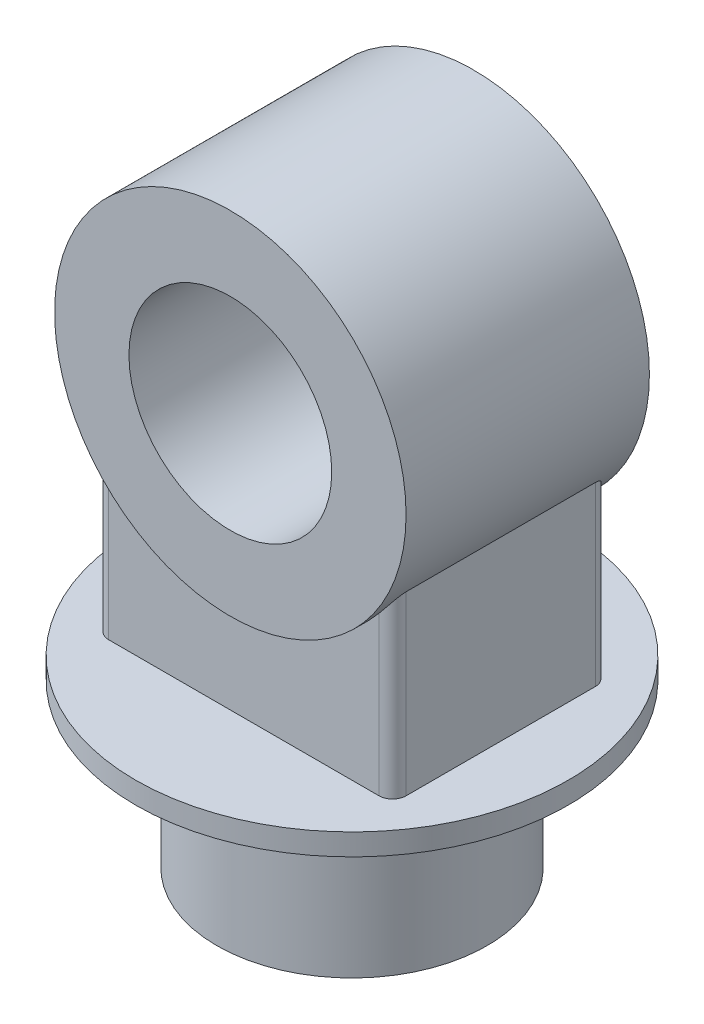
from build123d import *

# Parameters (mm, degrees)
SKETCH1_R                = 100
BOSS_EXTRUDE1_DEPTH      = 120
SKETCH2_R                = 160
BOSS_EXTRUDE2_DEPTH      = 16
SKETCH3_R                = 130
SKETCH3_R_2              = 75
BOSS_EXTRUDE3_DEPTH      = 90
BOSS_EXTRUDE4_REACH      = 402.125
BOSS_EXTRUDE4_END_RADIUS = 130
SKETCH4_W                = 220
SKETCH4_H                = 160
FILLET1_R                = 10


with BuildPart() as part:
    # Sketch1 → Boss-Extrude1 (new body)
    with BuildSketch(Plane(origin=(0, 0, 0), x_dir=(1, 0, 0), z_dir=(0, 1, 0))):
        with Locations(Location((0, 0, 0), (0, 0, 270))):
            Circle(SKETCH1_R)
    extrude(amount=BOSS_EXTRUDE1_DEPTH)

    # Sketch2 → Boss-Extrude2 (add)
    with BuildSketch(Plane(origin=(0, 120, 0), x_dir=(1, 0, 0), z_dir=(0, 1, 0))):
        with Locations(Location((0, 0, 0), (0, 0, 270))):
            Circle(SKETCH2_R)
    extrude(amount=BOSS_EXTRUDE2_DEPTH)



with BuildPart() as body_2:
    # Sketch3 → Boss-Extrude3 (new, symmetric)
    with BuildSketch(Plane.XY):
        with Locations(Location((0, 336, 0), (0, 0, 180))):
            Circle(SKETCH3_R)
        with Locations(Location((0, 336, 0), (0, 0, 180))):
            Circle(SKETCH3_R_2, mode=Mode.SUBTRACT)
    extrude(amount=BOSS_EXTRUDE3_DEPTH, both=True)


with BuildPart() as part_1:
    add(part.part)

    add(body_2.part)  # Boss-Extrude4 merges body 2
    # Boss-Extrude4: up to this cylinder (the profile starts outside it)
    boss_extrude4_end = Plane(origin=(0, 336, 0), z_dir=(0, 0, -1)) * Cylinder(BOSS_EXTRUDE4_END_RADIUS, 1065.25, mode=Mode.PRIVATE)
    # Sketch4 → Boss-Extrude4 (add, up to the surface)
    with BuildSketch(Plane(origin=(0, 136, 0), x_dir=(1, 0, 0), z_dir=(0, 1, 0)), mode=Mode.PRIVATE) as boss_extrude4_sk1:
        Rectangle(SKETCH4_W, SKETCH4_H)
    boss_extrude4_tool1 = extrude(boss_extrude4_sk1.sketch, amount=BOSS_EXTRUDE4_REACH, mode=Mode.PRIVATE) - boss_extrude4_end
    add(boss_extrude4_tool1.solids().sort_by_distance((0, 136, 0))[0])

    # Fillet1
    fillet1_edges = [part_1.edges().sort_by_distance(p)[0] for p in [
        (-110, 201.358983849, 80),
        (-110, 201.358983849, -80),
        (110, 201.358983849, 80),
        (110, 201.358983849, -80),
    ]]
    fillet(fillet1_edges, radius=FILLET1_R)


solid = part_1.part
